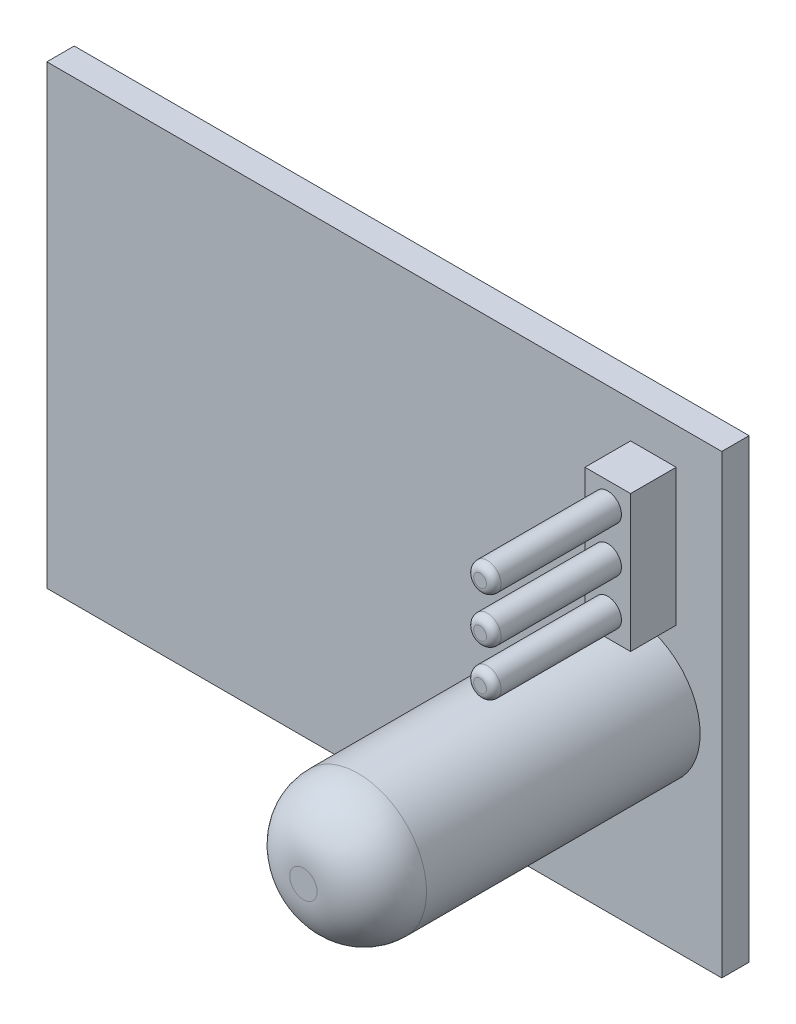
from build123d import *

# Parameters (mm, degrees)
SKIZZE1_W                       = 37
SKIZZE1_H                       = 25
AUFSATZ_LINEAR_AUSTRAGEN1_DEPTH = 1.5
SKIZZE3_R                       = 3.75
AUFSATZ_LINEAR_AUSTRAGEN2_DEPTH = 18
VERRUNDUNG1_R                   = 3
SKIZZE5_W                       = 2.5
SKIZZE5_H                       = 7.5
AUFSATZ_LINEAR_AUSTRAGEN3_DEPTH = 2.5
SKIZZE6_R                       = 0.75
AUFSATZ_LINEAR_AUSTRAGEN4_DEPTH = 7
LINEARES_MUSTER1_COUNT          = 3
LINEARES_MUSTER1_PITCH          = 2.5
VERRUNDUNG2_R                   = 0.4


with BuildPart() as part:
    # Skizze1 → Aufsatz-Linear austragen1 (new body)
    with BuildSketch(Plane.XY):
        Rectangle(SKIZZE1_W, SKIZZE1_H)
    extrude(amount=AUFSATZ_LINEAR_AUSTRAGEN1_DEPTH)

    # Skizze3 → Aufsatz-Linear austragen2 (add)
    with BuildSketch(Plane.XY.offset(1.5)):
        with Locations((13.564667913, -1.5)):
            Circle(SKIZZE3_R)
    extrude(amount=AUFSATZ_LINEAR_AUSTRAGEN2_DEPTH)

    # Verrundung1
    verrundung1_edges = [part.edges().sort_by_distance(p)[0] for p in [
        (9.814667913, -1.5, 19.5),
    ]]
    fillet(verrundung1_edges, radius=VERRUNDUNG1_R)



with BuildPart() as body_2:
    # Skizze5 → Aufsatz-Linear austragen3 (new body)
    with BuildSketch(Plane.XY.offset(1.5)):
        with Locations((14.75, 6.75)):
            Rectangle(SKIZZE5_W, SKIZZE5_H)
    extrude(amount=AUFSATZ_LINEAR_AUSTRAGEN3_DEPTH)


with BuildPart() as part_1:
    add(part.part)

    add(body_2.part)  # Aufsatz-Linear austragen4 merges body 2
    # Skizze6 → Aufsatz-Linear austragen4 (add)
    with BuildSketch(Plane.XY.offset(4)):
        with Locations((14.75, 9.25)):
            Circle(SKIZZE6_R)
    aufsatz_linear_austragen4 = extrude(amount=AUFSATZ_LINEAR_AUSTRAGEN4_DEPTH)

    # Lineares Muster1: Aufsatz-Linear austragen4 ×3
    with Locations(*[(0, -i * LINEARES_MUSTER1_PITCH, 0) for i in range(1, LINEARES_MUSTER1_COUNT)]):
        add(aufsatz_linear_austragen4)

    # Verrundung2
    verrundung2_edges = [part_1.edges().sort_by_distance(p)[0] for p in [
        (14, 9.25, 11),
        (14, 6.75, 11),
        (14, 4.25, 11),
    ]]
    fillet(verrundung2_edges, radius=VERRUNDUNG2_R)


solid = part_1.part
